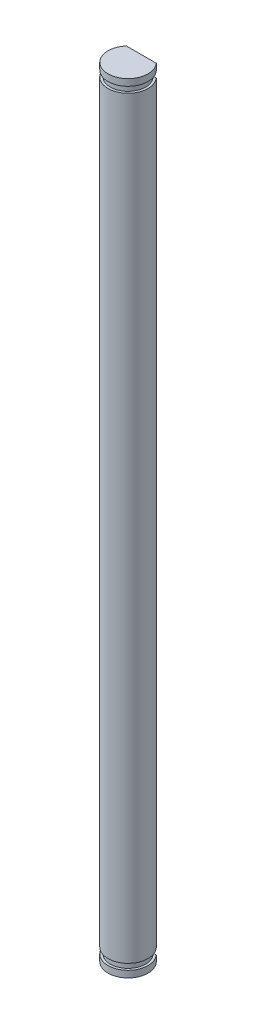
from build123d import *

# Parameters (mm, degrees)
BOSS_EXTRUDE1_DEPTH = 58.42
SKETCH2_W           = 0.35
SKETCH2_H           = 0.9


with BuildPart() as part:
    # Sketch1 → Boss-Extrude1 (new body, symmetric)
    with BuildSketch(Plane(origin=(0, 0, 0), x_dir=(1, 0, 0), z_dir=(0, 1, 0))):
        with BuildLine():
            Line((-2.236067977, 2), (2.236067977, 2))
            ThreePointArc((2.236067977, 2), (0, -3), (-2.236067977, 2))
        make_face()
    extrude(amount=BOSS_EXTRUDE1_DEPTH, both=True)

    # Sketch2 → Cut-Revolve1 (revolve, cut)
    with BuildSketch(Plane.XY):
        with Locations((2.825, 56.97)):
            Rectangle(SKETCH2_W, SKETCH2_H)
        with Locations((2.825, -56.97)):
            Rectangle(SKETCH2_W, SKETCH2_H)
    revolve(axis=Axis((0, 48.05613995, 0), (0, -1, 0)), mode=Mode.SUBTRACT)


solid = part.part
